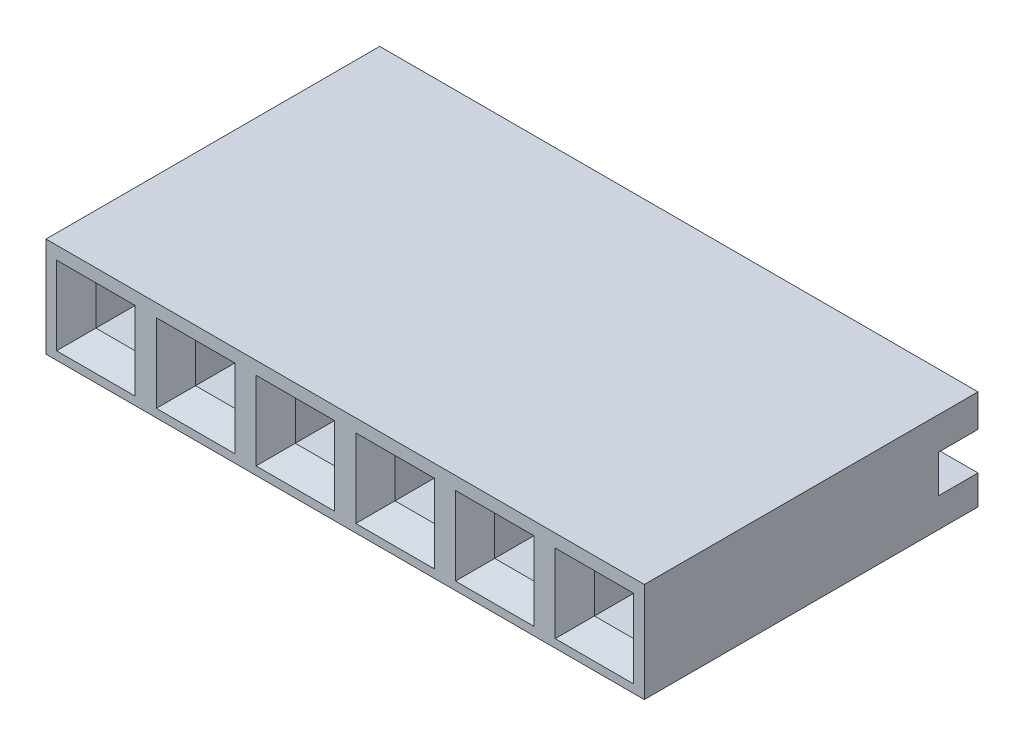
from build123d import *

# Parameters (mm, degrees)
BOSS_EXTRUDE1_DEPTH = 15.24
SKETCH2_W           = 2
SKETCH2_H           = 0.6
CUT_EXTRUDE1_DEPTH  = 5.5
SKETCH3_W           = 1
SKETCH3_H           = 1
CUT_EXTRUDE2_DEPTH  = 6
SKETCH4_W           = 2
SKETCH4_H           = 2
CUT_EXTRUDE3_DEPTH  = 0.5
CUT_EXTRUDE3_TAPER  = 45
LPATTERN1_COUNT     = 8
LPATTERN1_PITCH     = 2.54


with BuildPart() as part:
    # Sketch1 → Boss-Extrude1 (new body)
    with BuildSketch(Plane(origin=(0, 0, 0), x_dir=(0, 0, -1), z_dir=(1, 0, 0))):
        Polygon((8.5, 2.54), (0, 2.54), (0, 0), (8.5, 0), (8.5, 0.75), (7.5, 0.75), (7.5, 1.709993), (8.5, 1.709993), align=None)
    extrude(amount=-BOSS_EXTRUDE1_DEPTH)

    # Sketch2 → Cut-Extrude1 (cut)
    with BuildSketch(Plane(origin=(0, 0, -7.5), x_dir=(-1, 0, 0), z_dir=(0, 0, -1))):
        with Locations((1.27, 1.409993)):
            Rectangle(SKETCH2_W, SKETCH2_H)
    cut_extrude1 = extrude(amount=-CUT_EXTRUDE1_DEPTH, mode=Mode.SUBTRACT)

    # Sketch3 → Cut-Extrude2 (cut)
    with BuildSketch(Plane(origin=(0, 0, 0), x_dir=(-1, 0, 0), z_dir=(0, 0, -1))):
        with Locations((1.27, 1.209993)):
            Rectangle(SKETCH3_W, SKETCH3_H)
    cut_extrude2 = extrude(amount=CUT_EXTRUDE2_DEPTH, mode=Mode.SUBTRACT)

    # Sketch4 → Cut-Extrude3 (cut)
    with BuildSketch(Plane.XY):
        with Locations((-1.27, 1.209993)):
            Rectangle(SKETCH4_W, SKETCH4_H)
    cut_extrude3 = extrude(amount=-CUT_EXTRUDE3_DEPTH, taper=CUT_EXTRUDE3_TAPER, mode=Mode.SUBTRACT)

    # LPattern1: Cut-Extrude1, Cut-Extrude2, Cut-Extrude3 ×8
    with Locations(*[(-i * LPATTERN1_PITCH, 0, 0) for i in range(1, LPATTERN1_COUNT)]):
        add(cut_extrude1, mode=Mode.SUBTRACT)
        add(cut_extrude2, mode=Mode.SUBTRACT)
        add(cut_extrude3, mode=Mode.SUBTRACT)


solid = part.part
